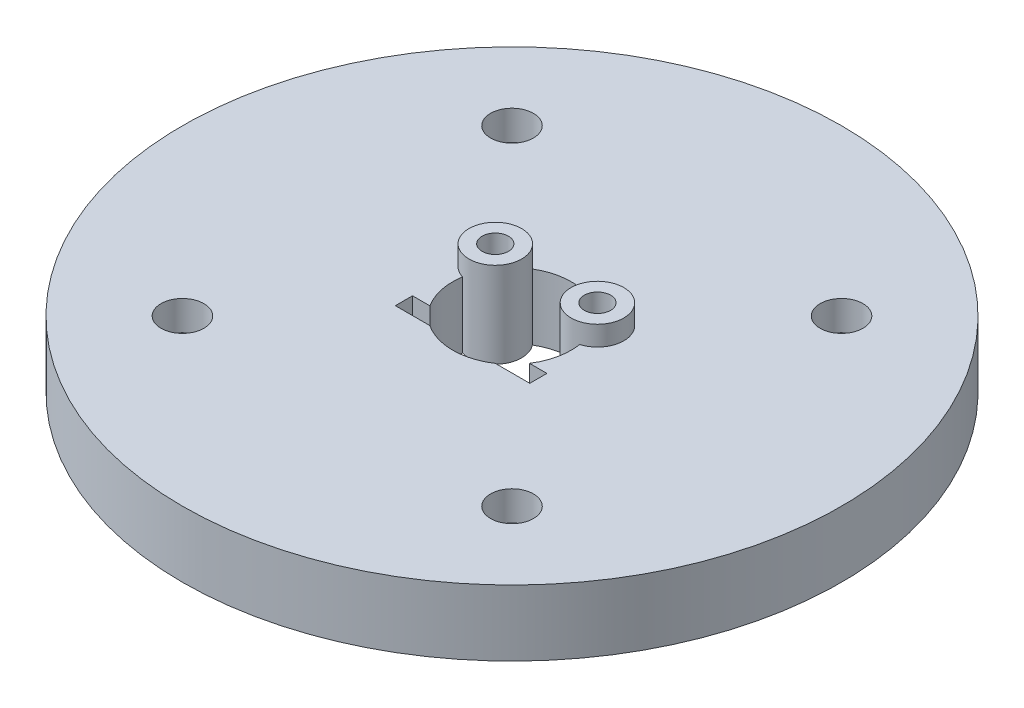
from build123d import *

# Parameters (mm, degrees)
SKIZZE1_R                       = 50
AUFSATZ_LINEAR_AUSTRAGEN1_DEPTH = 10
SKIZZE2_R                       = 1.7
SCHNITT_LINEAR_AUSTRAGEN1_DEPTH = 10
SKIZZE3_R                       = 3.25
SCHNITT_LINEAR_AUSTRAGEN2_DEPTH = 4.5
SKIZZE7_R                       = 9
SCHNITT_LINEAR_AUSTRAGEN5_DEPTH = 11
SKIZZE4_W                       = 20.4
SKIZZE4_H                       = 2.6
SCHNITT_LINEAR_AUSTRAGEN3_DEPTH = 10
AUFSATZ_LINEAR_START            = -10
SKIZZE5_R                       = 4
AUFSATZ_LINEAR_AUSTRAGEN2_DEPTH = 13
SKIZZE6_R                       = 2
SCHNITT_LINEAR_AUSTRAGEN4_DEPTH = 6


with BuildPart() as part:
    # Skizze1 → Aufsatz-Linear austragen1 (new body)
    with BuildSketch(Plane(origin=(0, 0, 0), x_dir=(1, 0, 0), z_dir=(0, 1, 0))):
        Circle(SKIZZE1_R)
    extrude(amount=AUFSATZ_LINEAR_AUSTRAGEN1_DEPTH)

    # Skizze2 → Schnitt-Linear austragen1 (cut)
    with BuildSketch(Plane(origin=(0, 10, 0), x_dir=(1, 0, 0), z_dir=(0, 1, 0))):
        with Locations((-25, 25)):
            Circle(SKIZZE2_R)
        with Locations((25, 25)):
            Circle(SKIZZE2_R)
        with Locations((25, -25)):
            Circle(SKIZZE2_R)
        with Locations((-25, -25)):
            Circle(SKIZZE2_R)
    extrude(amount=-SCHNITT_LINEAR_AUSTRAGEN1_DEPTH, mode=Mode.SUBTRACT)

    # Skizze3 → Schnitt-Linear austragen2 (cut)
    with BuildSketch(Plane(origin=(0, 10, 0), x_dir=(1, 0, 0), z_dir=(0, 1, 0))):
        with Locations((-25, 25)):
            Circle(SKIZZE3_R)
        with Locations((25, 25)):
            Circle(SKIZZE3_R)
        with Locations((25, -25)):
            Circle(SKIZZE3_R)
        with Locations((-25, -25)):
            Circle(SKIZZE3_R)
    extrude(amount=-SCHNITT_LINEAR_AUSTRAGEN2_DEPTH, mode=Mode.SUBTRACT)

    # Skizze7 → Schnitt-Linear austragen5 (cut, through all)
    with BuildSketch(Plane.XZ):
        Circle(SKIZZE7_R)
    extrude(amount=-SCHNITT_LINEAR_AUSTRAGEN5_DEPTH, mode=Mode.SUBTRACT)

    # Skizze4 → Schnitt-Linear austragen3 (cut)
    with BuildSketch(Plane(origin=(0, 10, 0), x_dir=(1, 0, 0), z_dir=(0, 1, 0))):
        with Locations((0, -6.2)):
            Rectangle(SKIZZE4_W, SKIZZE4_H)
    extrude(amount=-SCHNITT_LINEAR_AUSTRAGEN3_DEPTH, mode=Mode.SUBTRACT)

    # Skizze5 → Aufsatz-Linear austragen2 (add)
    with BuildSketch(Plane(origin=(0, 10, 0), x_dir=(1, 0, 0), z_dir=(0, 1, 0)).offset(AUFSATZ_LINEAR_START)):
        with Locations((-7.75, 5.215)):
            Circle(SKIZZE5_R)
        with BuildLine():
            ThreePointArc((-6.220782003, 6.503988874), (-9.409308992, 6.331554373), (-8.368075659, 3.312900507))
            ThreePointArc((-8.368075659, 3.312900507), (-7.466890464, 5.02449468), (-6.220782003, 6.503988874))
        make_face(mode=Mode.SUBTRACT)
        with Locations((7.75, 5.215)):
            Circle(SKIZZE5_R)
        with BuildLine():
            ThreePointArc((8.368075659, 3.312900507), (9.409308992, 6.331554373), (6.220782003, 6.503988874))
            ThreePointArc((6.220782003, 6.503988874), (7.466890464, 5.02449468), (8.368075659, 3.312900507))
        make_face(mode=Mode.SUBTRACT)
    extrude(amount=AUFSATZ_LINEAR_AUSTRAGEN2_DEPTH)

    # Skizze6 → Schnitt-Linear austragen4 (cut)
    with BuildSketch(Plane(origin=(0, 12.999999992, 0), x_dir=(1, 0, 0), z_dir=(0, 1, 0))):
        with Locations((-7.75, 5.215)):
            Circle(SKIZZE6_R)
        with Locations((7.75, 5.215)):
            Circle(SKIZZE6_R)
    extrude(amount=-SCHNITT_LINEAR_AUSTRAGEN4_DEPTH, mode=Mode.SUBTRACT)


solid = part.part
